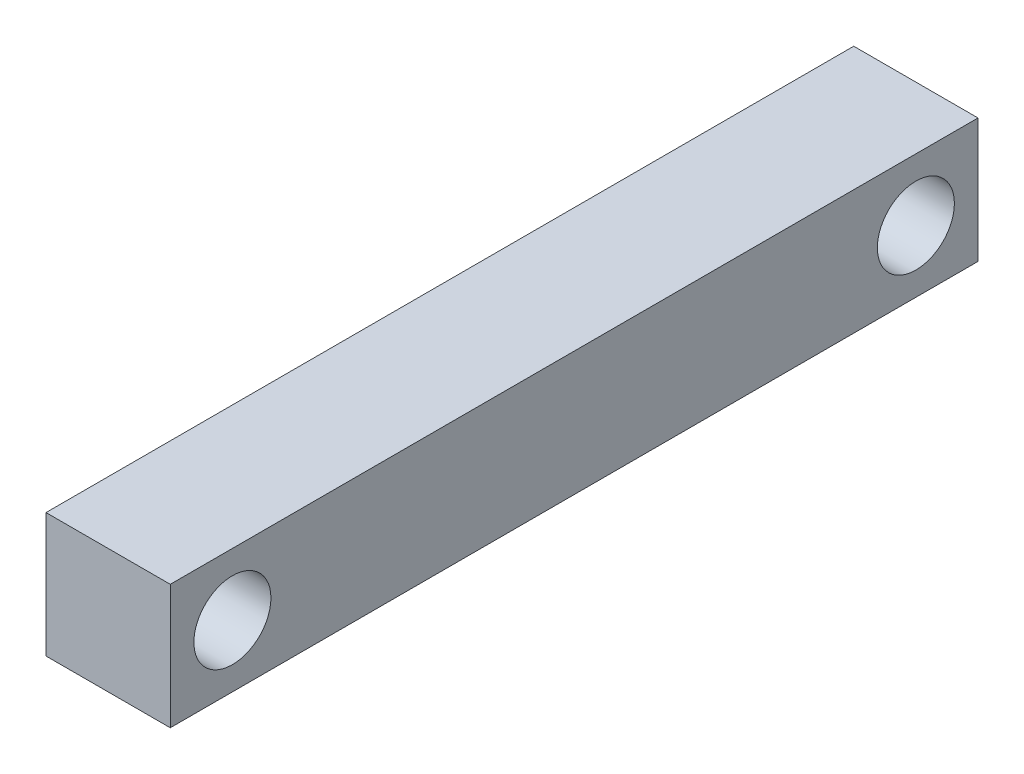
from build123d import *

# Parameters (mm, degrees)
SKETCH1_W           = 65
SKETCH1_H           = 10
SKETCH1_R           = 3.1
BOSS_EXTRUDE1_DEPTH = 10


with BuildPart() as part:
    # Sketch1 → Boss-Extrude1 (new body)
    with BuildSketch(Plane(origin=(0, 0, 0), x_dir=(0, 0, -1), z_dir=(1, 0, 0))):
        Rectangle(SKETCH1_W, SKETCH1_H)
        with Locations((-27.5, 0)):
            Circle(SKETCH1_R, mode=Mode.SUBTRACT)
        with Locations((27.5, 0)):
            Circle(SKETCH1_R, mode=Mode.SUBTRACT)
    extrude(amount=BOSS_EXTRUDE1_DEPTH)


solid = part.part
